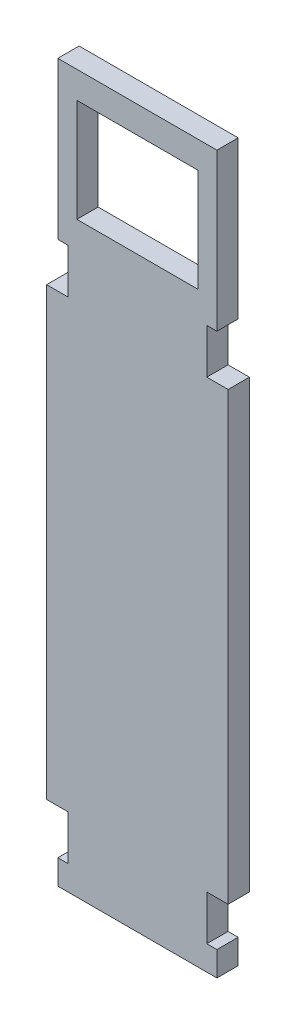
from build123d import *

# Parameters (mm, degrees)
SKETCH1_W           = 27
SKETCH1_H           = 23
BOSS_EXTRUDE1_DEPTH = 4.75


with BuildPart() as part:
    # Sketch1 → Boss-Extrude1 (new body)
    with BuildSketch(Plane.XY):
        Polygon((-4.75, 10), (-4.75, 109.5), (0, 109.5), (0, 119.5), (-2.25, 119.5), (-2.25, 154.5), (33.25, 154.5), (33.25, 119.5), (31, 119.5), (31, 109.5), (35.75, 109.5), (35.75, 10), (31, 10), (31, 0), (33.25, 0), (33.25, -5.5), (-2.25, -5.5), (-2.25, 0), (0, 0), (0, 10), align=None)
        with Locations((15.5, 137)):
            Rectangle(SKETCH1_W, SKETCH1_H, mode=Mode.SUBTRACT)
    extrude(amount=BOSS_EXTRUDE1_DEPTH)


solid = part.part
